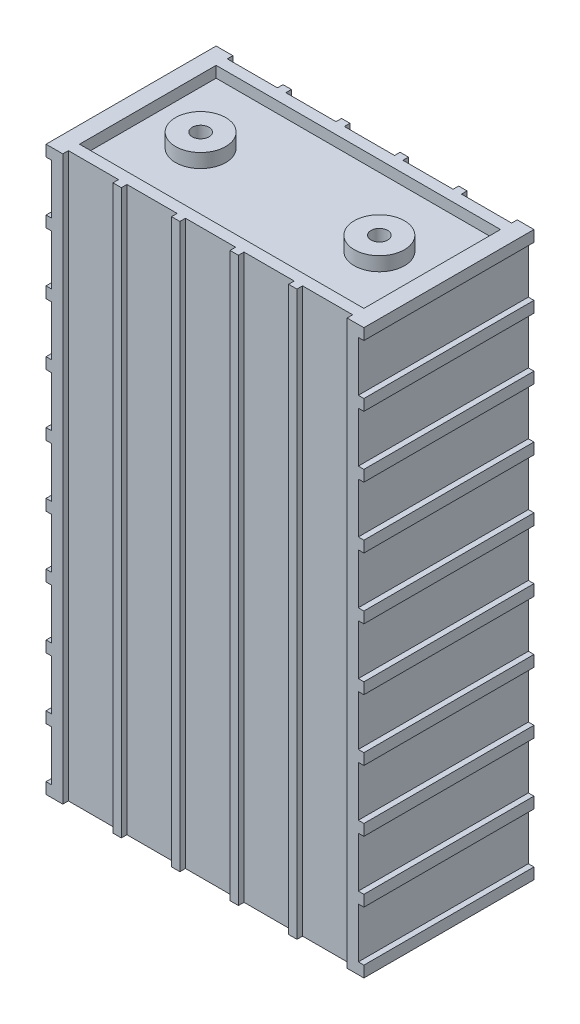
from build123d import *

# Parameters (mm, degrees)
CROQUIS1_W                = 114
CROQUIS1_H                = 202
SALIENTE_EXTRUIR1_DEPTH   = 30.5
CROQUIS2_W                = 2
CROQUIS2_H                = 18
CORTAR_EXTRUIR1_DEPTH     = 62
MATRIZL1_COUNT            = 9
MATRIZL1_PITCH            = 22
SIMETR_A1_COPY_1_SKETCH_W = 2
SIMETR_A1_COPY_1_SKETCH_H = 18
SIMETR_A1_COPY_1_DEPTH    = 62
SIMETR_A1_COPY_2_SKETCH_W = 2
SIMETR_A1_COPY_2_SKETCH_H = 18
SIMETR_A1_COPY_2_DEPTH    = 62
SIMETR_A1_COPY_3_SKETCH_W = 2
SIMETR_A1_COPY_3_SKETCH_H = 18
SIMETR_A1_COPY_3_DEPTH    = 62
SIMETR_A1_COPY_4_SKETCH_W = 2
SIMETR_A1_COPY_4_SKETCH_H = 18
SIMETR_A1_COPY_4_DEPTH    = 62
SIMETR_A1_COPY_5_SKETCH_W = 2
SIMETR_A1_COPY_5_SKETCH_H = 18
SIMETR_A1_COPY_5_DEPTH    = 62
SIMETR_A1_COPY_6_SKETCH_W = 2
SIMETR_A1_COPY_6_SKETCH_H = 18
SIMETR_A1_COPY_6_DEPTH    = 62
SIMETR_A1_COPY_7_SKETCH_W = 2
SIMETR_A1_COPY_7_SKETCH_H = 18
SIMETR_A1_COPY_7_DEPTH    = 62
SIMETR_A1_COPY_8_SKETCH_W = 2
SIMETR_A1_COPY_8_SKETCH_H = 18
SIMETR_A1_COPY_8_DEPTH    = 62
CROQUIS3_W                = 18
CROQUIS3_H                = 2
CORTAR_EXTRUIR2_DEPTH     = 203
CROQUIS4_W                = 102
CROQUIS4_H                = 49
CORTAR_EXTRUIR3_DEPTH     = 4
CROQUIS5_R                = 9
SALIENTE_EXTRUIR2_DEPTH   = 5
CROQUIS6_R                = 3
CORTAR_EXTRUIR4_DEPTH     = 10


with BuildPart() as part:
    # Croquis1 → Saliente-Extruir1 (new body, symmetric)
    with BuildSketch(Plane.XY):
        Rectangle(CROQUIS1_W, CROQUIS1_H)
    extrude(amount=SALIENTE_EXTRUIR1_DEPTH, both=True)

    # Croquis2 → Cortar-Extruir1 (cut, through all)
    with BuildSketch(Plane.XY.offset(30.5)):
        with Locations((56, 88)):
            Rectangle(CROQUIS2_W, CROQUIS2_H)
    cortar_extruir1 = extrude(amount=-CORTAR_EXTRUIR1_DEPTH, mode=Mode.SUBTRACT)

    # MatrizL1: Cortar-Extruir1 ×9
    with Locations(*[(0, -i * MATRIZL1_PITCH, 0) for i in range(1, MATRIZL1_COUNT)]):
        add(cortar_extruir1, mode=Mode.SUBTRACT)

    # Simetría1: Cortar-Extruir1 across plane
    add(cortar_extruir1.mirror(Plane(origin=(0, 0, 0), x_dir=(0, 0, 1), z_dir=(1, 0, 0))), mode=Mode.SUBTRACT)

    # Simetría1 copy 1 sketch → Simetría1 copy 1 (cut, through all)
    with BuildSketch(Plane(origin=(0, -22, 30.5), x_dir=(-1, 0, 0), z_dir=(0, 0, 1))):
        with Locations((56, -88)):
            Rectangle(SIMETR_A1_COPY_1_SKETCH_W, SIMETR_A1_COPY_1_SKETCH_H)
    extrude(amount=-SIMETR_A1_COPY_1_DEPTH, mode=Mode.SUBTRACT)

    # Simetría1 copy 2 sketch → Simetría1 copy 2 (cut, through all)
    with BuildSketch(Plane(origin=(0, -44, 30.5), x_dir=(-1, 0, 0), z_dir=(0, 0, 1))):
        with Locations((56, -88)):
            Rectangle(SIMETR_A1_COPY_2_SKETCH_W, SIMETR_A1_COPY_2_SKETCH_H)
    extrude(amount=-SIMETR_A1_COPY_2_DEPTH, mode=Mode.SUBTRACT)

    # Simetría1 copy 3 sketch → Simetría1 copy 3 (cut, through all)
    with BuildSketch(Plane(origin=(0, -66, 30.5), x_dir=(-1, 0, 0), z_dir=(0, 0, 1))):
        with Locations((56, -88)):
            Rectangle(SIMETR_A1_COPY_3_SKETCH_W, SIMETR_A1_COPY_3_SKETCH_H)
    extrude(amount=-SIMETR_A1_COPY_3_DEPTH, mode=Mode.SUBTRACT)

    # Simetría1 copy 4 sketch → Simetría1 copy 4 (cut, through all)
    with BuildSketch(Plane(origin=(0, -88, 30.5), x_dir=(-1, 0, 0), z_dir=(0, 0, 1))):
        with Locations((56, -88)):
            Rectangle(SIMETR_A1_COPY_4_SKETCH_W, SIMETR_A1_COPY_4_SKETCH_H)
    extrude(amount=-SIMETR_A1_COPY_4_DEPTH, mode=Mode.SUBTRACT)

    # Simetría1 copy 5 sketch → Simetría1 copy 5 (cut, through all)
    with BuildSketch(Plane(origin=(0, -110, 30.5), x_dir=(-1, 0, 0), z_dir=(0, 0, 1))):
        with Locations((56, -88)):
            Rectangle(SIMETR_A1_COPY_5_SKETCH_W, SIMETR_A1_COPY_5_SKETCH_H)
    extrude(amount=-SIMETR_A1_COPY_5_DEPTH, mode=Mode.SUBTRACT)

    # Simetría1 copy 6 sketch → Simetría1 copy 6 (cut, through all)
    with BuildSketch(Plane(origin=(0, -132, 30.5), x_dir=(-1, 0, 0), z_dir=(0, 0, 1))):
        with Locations((56, -88)):
            Rectangle(SIMETR_A1_COPY_6_SKETCH_W, SIMETR_A1_COPY_6_SKETCH_H)
    extrude(amount=-SIMETR_A1_COPY_6_DEPTH, mode=Mode.SUBTRACT)

    # Simetría1 copy 7 sketch → Simetría1 copy 7 (cut, through all)
    with BuildSketch(Plane(origin=(0, -154, 30.5), x_dir=(-1, 0, 0), z_dir=(0, 0, 1))):
        with Locations((56, -88)):
            Rectangle(SIMETR_A1_COPY_7_SKETCH_W, SIMETR_A1_COPY_7_SKETCH_H)
    extrude(amount=-SIMETR_A1_COPY_7_DEPTH, mode=Mode.SUBTRACT)

    # Simetría1 copy 8 sketch → Simetría1 copy 8 (cut, through all)
    with BuildSketch(Plane(origin=(0, -176, 30.5), x_dir=(-1, 0, 0), z_dir=(0, 0, 1))):
        with Locations((56, -88)):
            Rectangle(SIMETR_A1_COPY_8_SKETCH_W, SIMETR_A1_COPY_8_SKETCH_H)
    extrude(amount=-SIMETR_A1_COPY_8_DEPTH, mode=Mode.SUBTRACT)

    # Croquis3 → Cortar-Extruir2 (cut, through all)
    with BuildSketch(Plane(origin=(0, 101, 0), x_dir=(1, 0, 0), z_dir=(0, 1, 0))):
        with Locations((0, 29.5)):
            Rectangle(CROQUIS3_W, CROQUIS3_H)
        with Locations((21, 29.5)):
            Rectangle(CROQUIS3_W, CROQUIS3_H)
        with Locations((42, 29.5)):
            Rectangle(CROQUIS3_W, CROQUIS3_H)
        with Locations((-42, 29.5)):
            Rectangle(CROQUIS3_W, CROQUIS3_H)
        with Locations((-21, 29.5)):
            Rectangle(CROQUIS3_W, CROQUIS3_H)
    cortar_extruir2 = extrude(amount=-CORTAR_EXTRUIR2_DEPTH, mode=Mode.SUBTRACT)

    # Simetría2: Cortar-Extruir2 across plane
    add(cortar_extruir2.mirror(Plane.XY), mode=Mode.SUBTRACT)

    # Croquis4 → Cortar-Extruir3 (cut)
    with BuildSketch(Plane(origin=(0, 101, 0), x_dir=(1, 0, 0), z_dir=(0, 1, 0))):
        Rectangle(CROQUIS4_W, CROQUIS4_H)
    extrude(amount=-CORTAR_EXTRUIR3_DEPTH, mode=Mode.SUBTRACT)

    # Croquis5 → Saliente-Extruir2 (add)
    with BuildSketch(Plane(origin=(0, 97, 0), x_dir=(1, 0, 0), z_dir=(0, 1, 0))):
        with Locations((32.053240518, 0)):
            Circle(CROQUIS5_R)
    saliente_extruir2 = extrude(amount=SALIENTE_EXTRUIR2_DEPTH)

    # Croquis6 → Cortar-Extruir4 (cut)
    with BuildSketch(Plane(origin=(0, 102, 0), x_dir=(1, 0, 0), z_dir=(0, 1, 0))):
        with Locations((32.053240518, 0)):
            Circle(CROQUIS6_R)
    cortar_extruir4 = extrude(amount=-CORTAR_EXTRUIR4_DEPTH, mode=Mode.SUBTRACT)

    # Simetría4: Saliente-Extruir2, Cortar-Extruir4 across plane
    add(saliente_extruir2.mirror(Plane(origin=(0, 0, 0), x_dir=(0, 0, 1), z_dir=(1, 0, 0))))
    add(cortar_extruir4.mirror(Plane(origin=(0, 0, 0), x_dir=(0, 0, 1), z_dir=(1, 0, 0))), mode=Mode.SUBTRACT)


solid = part.part
